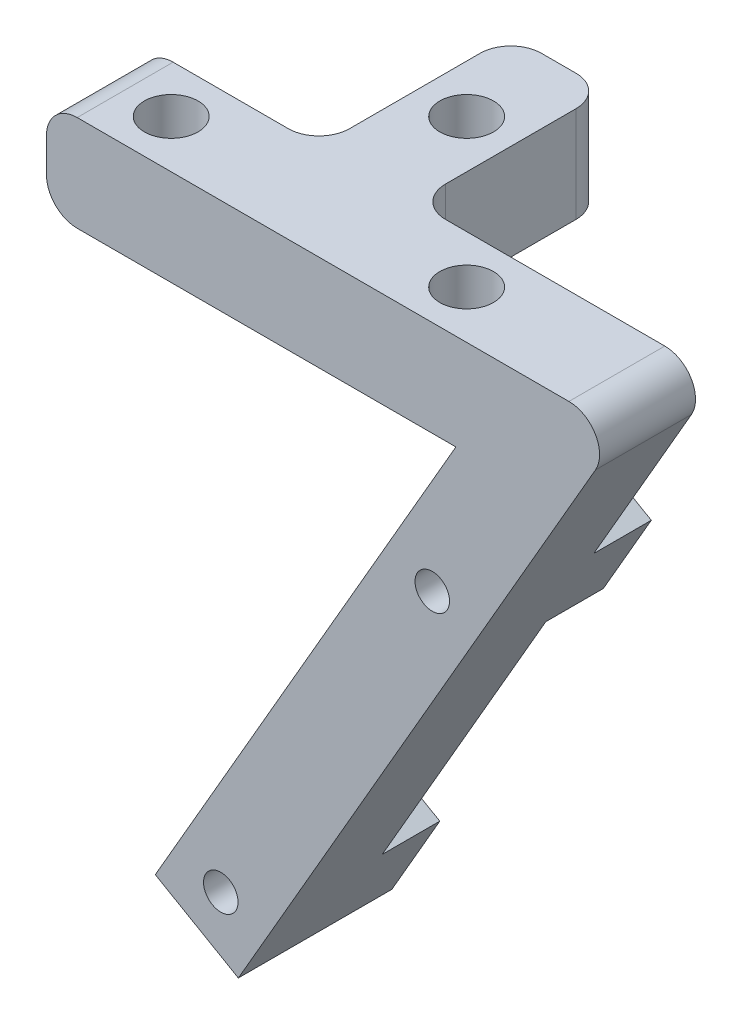
from build123d import *

# Parameters (mm, degrees)
BOSS_EXTRUDE2_DEPTH = 6.35
SKETCH5_R           = 1.778
CUT_EXTRUDE1_DEPTH  = 6.35
SKETCH7_W           = 6.35
SKETCH7_H           = 12.7
BOSS_EXTRUDE3_DEPTH = 6.35
SKETCH8_R           = 1.778
CUT_EXTRUDE3_DEPTH  = 6.35
SKETCH9_R           = 1.143
CUT_EXTRUDE4_DEPTH  = 12.7
BOSS_EXTRUDE5_DEPTH = 3.81
FILLET1_R           = 2.032
SKETCH12_R          = 1.143
CUT_EXTRUDE5_DEPTH  = 12.7


with BuildPart() as part:
    # Sketch2 → Boss-Extrude2 (new body)
    with BuildSketch(Plane.XY):
        Polygon((0, 0), (38.1, 0), (12.7, -43.994090512), (7.200738686, -40.819090512), (27.101477372, -6.35), (0, -6.35), align=None)
    extrude(amount=BOSS_EXTRUDE2_DEPTH)

    # Sketch5 → Cut-Extrude1 (cut)
    with BuildSketch(Plane(origin=(0, 0, 0), x_dir=(1, 0, 0), z_dir=(0, 1, 0))):
        with Locations((5.08, -3.175)):
            Circle(SKETCH5_R)
        with Locations((24.638, -3.175)):
            Circle(SKETCH5_R)
    extrude(amount=-CUT_EXTRUDE1_DEPTH, mode=Mode.SUBTRACT)

    # Sketch7 → Boss-Extrude3 (add)
    with BuildSketch(Plane(origin=(0, 0, 0), x_dir=(1, 0, 0), z_dir=(0, 1, 0))):
        with Locations((14.859, 6.35)):
            Rectangle(SKETCH7_W, SKETCH7_H)
    extrude(amount=-BOSS_EXTRUDE3_DEPTH)

    # Sketch8 → Cut-Extrude3 (cut)
    with BuildSketch(Plane(origin=(0, 0, 0), x_dir=(1, 0, 0), z_dir=(0, 1, 0))):
        with Locations((14.859, 6.604)):
            Circle(SKETCH8_R)
    extrude(amount=-CUT_EXTRUDE3_DEPTH, mode=Mode.SUBTRACT)

    # Sketch9 → Cut-Extrude4 (cut)
    with BuildSketch(Plane.XY.offset(6.35)):
        with Locations((11.537869343, -39.656959855)):
            Circle(SKETCH9_R)
        with Locations((25.537841343, -15.408297047)):
            Circle(SKETCH9_R)
    extrude(amount=-CUT_EXTRUDE4_DEPTH, mode=Mode.SUBTRACT)

    # Sketch11 → Boss-Extrude5 (add)
    with BuildSketch(Plane(origin=(0, 0, 0), x_dir=(-1, 0, 0), z_dir=(0, 0, -1))):
        Polygon((-29.874972, -14.24616639), (-24.375710686, -11.07116639), (-21.200710686, -16.570427704), (-26.699972, -19.745427704), align=None)
        Polygon((-15.875, -38.494829198), (-10.375738686, -35.319829198), (-7.200738686, -40.819090512), (-12.7, -43.994090512), align=None)
    extrude(amount=BOSS_EXTRUDE5_DEPTH)

    # Fillet1
    fillet1_edges = [part.edges().sort_by_distance(p)[0] for p in [
        (0, 0, 3.175),
        (38.1, 0, 3.175),
        (0, -6.35, 3.175),
        (11.684, -3.175, 0),
        (11.684, -3.175, -12.7),
        (18.034, -3.175, -12.7),
        (18.034, -3.175, 0),
    ]]
    fillet(fillet1_edges, radius=FILLET1_R)

    # Sketch12 → Cut-Extrude5 (cut)
    with BuildSketch(Plane.XY.offset(6.35)):
        with Locations((25.537841343, -15.408297047)):
            Circle(SKETCH12_R)
        with Locations((11.537869343, -39.656959855)):
            Circle(SKETCH12_R)
    extrude(amount=-CUT_EXTRUDE5_DEPTH, mode=Mode.SUBTRACT)


solid = part.part
